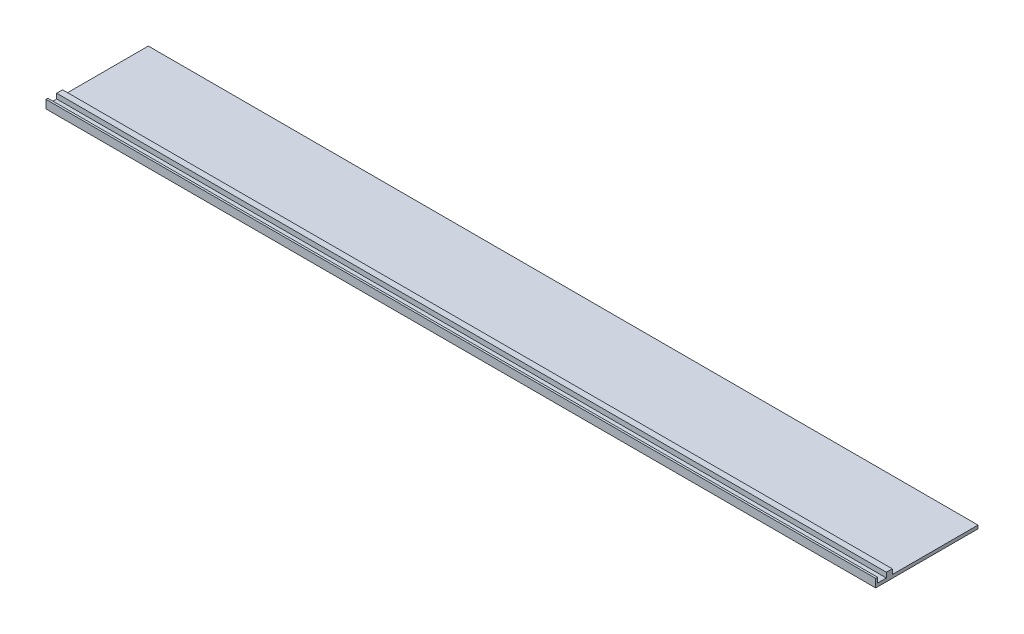
from build123d import *

# Parameters (mm, degrees)
EXTRUDE_1_DEPTH = 1500


with BuildPart() as part:
    # Эскиз1 → Бобышка-Вытянуть1 (new body)
    with BuildSketch(Plane(origin=(0, 0, 0), x_dir=(0, 0, -1), z_dir=(1, 0, 0))):
        Polygon((-92.5, 0), (92.5, 0), (92.5, 6), (-62.515671886, 6), (-62.515671886, 15), (-73.247976073, 15), (-73.247976073, 6), (-88.98868888, 6), (-88.98868888, 15), (-92.5, 15), align=None)
    extrude(amount=EXTRUDE_1_DEPTH)


solid = part.part
